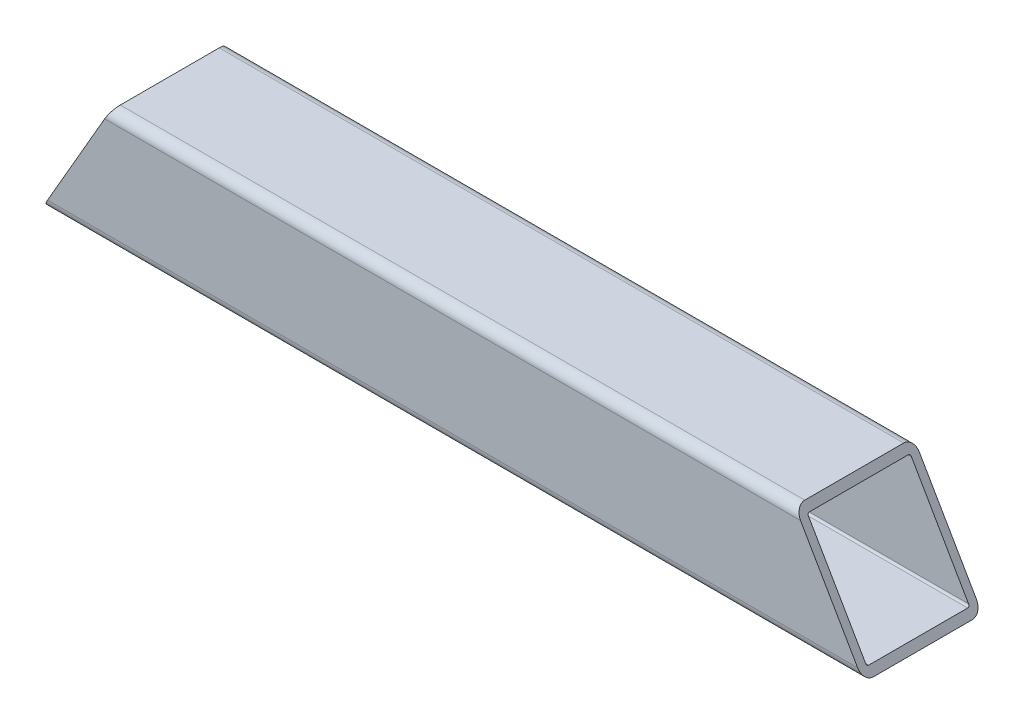
from build123d import *

# Parameters (mm, degrees)
EXTRUDE_THIN1_DEPTH     = 131.7625
CUT_EXTRUDE1_DEPTH      = 1
CUT_EXTRUDE1_DEPTH_BACK = 39.1
CUT_EXTRUDE2_DEPTH      = 1
CUT_EXTRUDE2_DEPTH_BACK = 39.1


with BuildPart() as part:
    # Sketch1 → Extrude-Thin1 (new body, symmetric)
    with BuildSketch(Plane(origin=(0, 0, 0), x_dir=(0, 0, -1), z_dir=(1, 0, 0))):
        with BuildLine():
            Line((-15.875, 19.05), (15.875, 19.05))
            ThreePointArc((15.875, 19.05), (18.12006403, 18.12006403), (19.05, 15.875))
            Line((19.05, 15.875), (19.05, -15.875))
            ThreePointArc((19.05, -15.875), (18.12006403, -18.12006403), (15.875, -19.05))
            Line((15.875, -19.05), (-15.875, -19.05))
            ThreePointArc((-15.875, -19.05), (-18.12006403, -18.12006403), (-19.05, -15.875))
            Line((-19.05, -15.875), (-19.05, 15.875))
            ThreePointArc((-19.05, 15.875), (-18.12006403, 18.12006403), (-15.875, 19.05))
        make_face()
        with BuildLine():
            Line((-15.875, 16.51), (15.875, 16.51))
            ThreePointArc((15.875, 16.51), (16.324012806, 16.324012806), (16.51, 15.875))
            Line((16.51, 15.875), (16.51, -15.875))
            ThreePointArc((16.51, -15.875), (16.324012806, -16.324012806), (15.875, -16.51))
            Line((15.875, -16.51), (-15.875, -16.51))
            ThreePointArc((-15.875, -16.51), (-16.324012806, -16.324012806), (-16.51, -15.875))
            Line((-16.51, -15.875), (-16.51, 15.875))
            ThreePointArc((-16.51, 15.875), (-16.324012806, 16.324012806), (-15.875, 16.51))
        make_face(mode=Mode.SUBTRACT)
    extrude(amount=EXTRUDE_THIN1_DEPTH, both=True)

    # Sketch2 → Cut-Extrude1 (cut, two sides)
    with BuildSketch(Plane.XY.offset(19.05)) as cut_extrude1_sk:
        Polygon((-403.027472584, -488.894714829), (-131.7625, -19.05), (-109.765454744, 19.05), (161.49951784, 488.894714829), (-778.189911818, 1031.424659996), (-1342.716902241, 53.635230339), align=None)
    extrude(amount=CUT_EXTRUDE1_DEPTH, mode=Mode.SUBTRACT)
    extrude(cut_extrude1_sk.sketch, amount=-CUT_EXTRUDE1_DEPTH_BACK, mode=Mode.SUBTRACT)

    # Sketch3 → Cut-Extrude2 (cut, two sides)
    with BuildSketch(Plane.XY.offset(19.05)) as cut_extrude2_sk:
        Polygon((403.027472584, -488.894714829), (131.7625, -19.05), (109.765454744, 19.05), (-161.49951784, 488.894714829), (778.189911818, 1031.424659996), (1342.716902241, 53.635230339), align=None)
    extrude(amount=CUT_EXTRUDE2_DEPTH, mode=Mode.SUBTRACT)
    extrude(cut_extrude2_sk.sketch, amount=-CUT_EXTRUDE2_DEPTH_BACK, mode=Mode.SUBTRACT)


solid = part.part
